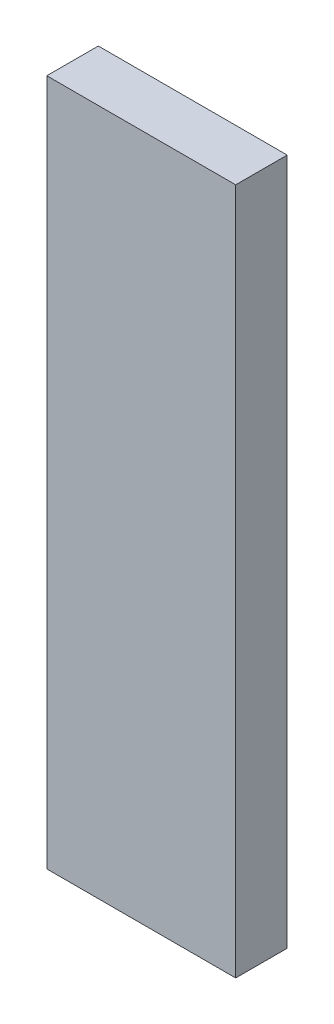
from build123d import *

# Parameters (mm, degrees)
SKETCH1_W           = 11
SKETCH1_H           = 40
BOSS_EXTRUDE1_DEPTH = 3


with BuildPart() as part:
    # Sketch1 → Boss-Extrude1 (new body)
    with BuildSketch(Plane.XY):
        with Locations((5.5, 20)):
            Rectangle(SKETCH1_W, SKETCH1_H)
    extrude(amount=BOSS_EXTRUDE1_DEPTH)


solid = part.part
